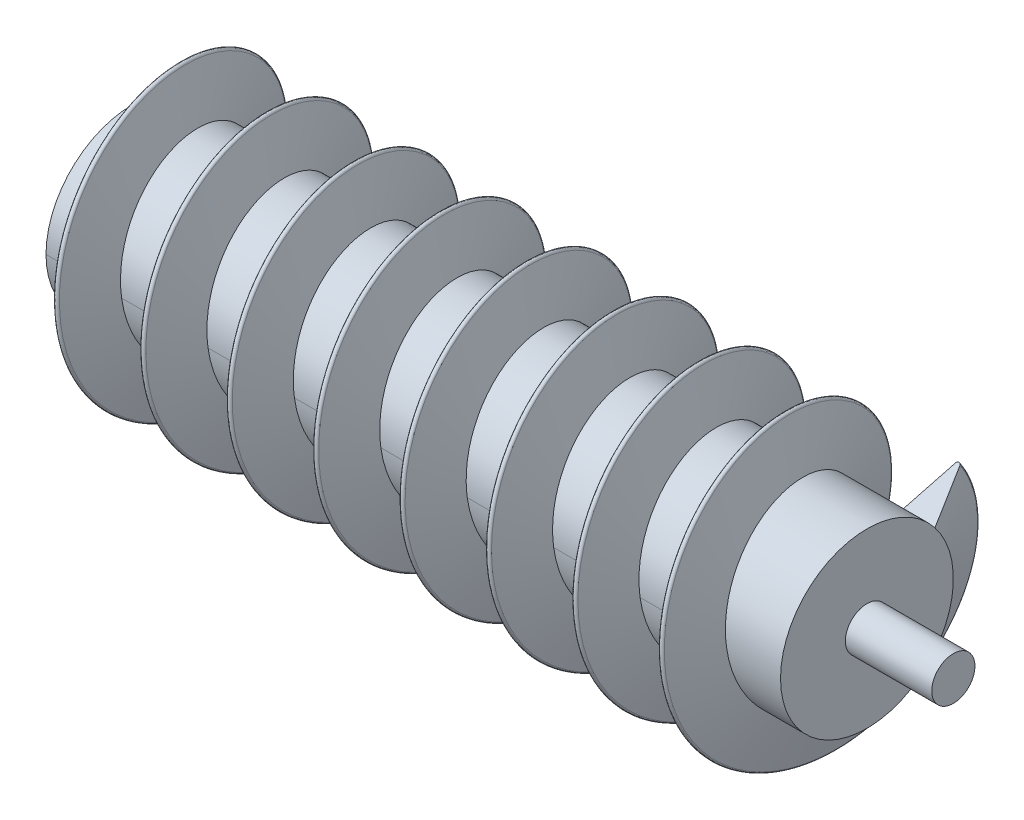
from build123d import *

# Parameters (mm, degrees)
SWEEP4_PITCH       = 20
SWEEP4_HEIGHT      = 162
SWEEP4_RADIUS      = 31.5
SWEEP4_START_ANGLE = 180


with BuildPart() as part:
    # Sketch1 → Revolve1 (revolve)
    with BuildSketch(Plane.XY, mode=Mode.PRIVATE) as revolve1_sk:
        Polygon((0, 0), (190, 0), (190, 5), (170, 5), (170, 20), (0, 20), align=None)
    revolve(revolve1_sk.sketch.rotate(Axis((0, 0, 0), (1, 0, 0)), 90), axis=Axis((0, 0, 0), (1, 0, 0)))

    # Sweep4: sweep along a helix
    with BuildLine() as sweep4_path:
        add(Helix(SWEEP4_PITCH, SWEEP4_HEIGHT, SWEEP4_RADIUS, center=(0, 0, 0), direction=(1, 0, 0), mode=Mode.PRIVATE).rotate(Axis((0, 0, 0), (1, 0, 0)), SWEEP4_START_ANGLE))
    # Sketch12 → Sweep4 (sweep)
    with BuildSketch(Plane(origin=(0, 0, 0), x_dir=(1, 0, 0), z_dir=(0, 1, 0))):
        with BuildLine():
            Line((0, 20), (3.316077387, 31.101780037))
            ThreePointArc((3.316077387, 31.101780037), (3.840077602, 31.489229613), (4.358475871, 31.094316162))
            Line((4.358475871, 31.094316162), (7.5, 20))
            Line((7.5, 20), (7.5, 18.955063124))
            Line((7.5, 18.955063124), (0, 18.955063124))
            Line((0, 18.955063124), (0, 20))
        make_face()
    sweep(path=sweep4_path.line, is_frenet=True)


solid = part.part
